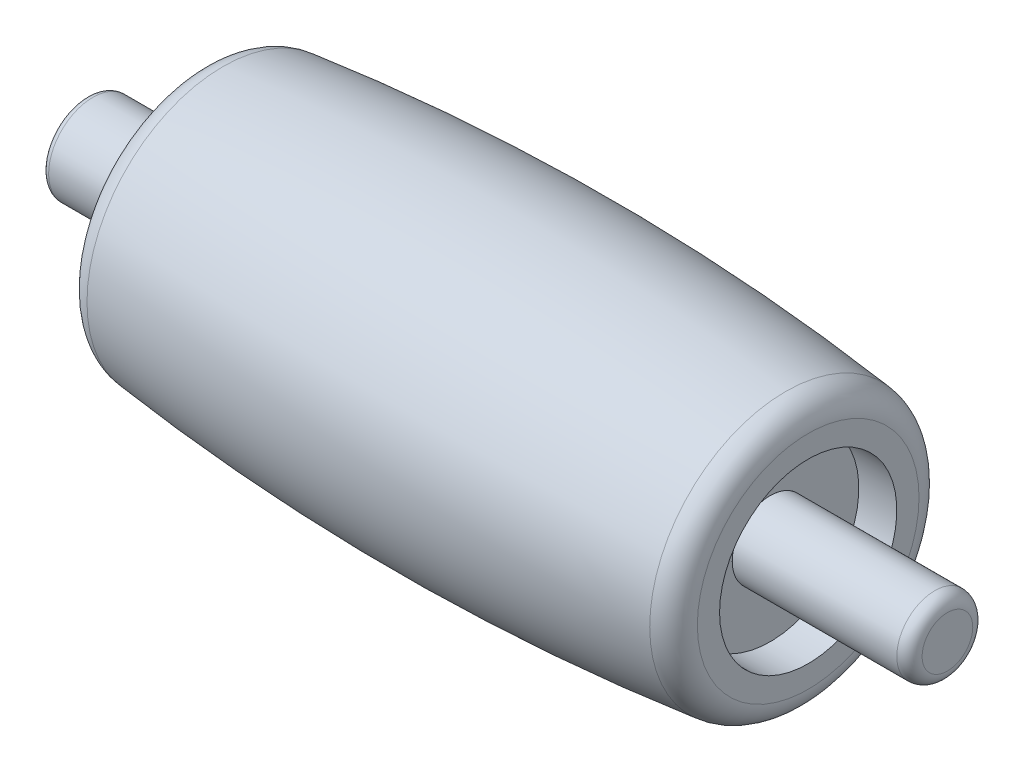
from build123d import *

# Parameters (mm, degrees)
SKETCH2_R           = 1.5
BOSS_EXTRUDE1_DEPTH = 7
SKETCH3_R           = 1.75
BOSS_EXTRUDE2_DEPTH = 6
FILLET1_R           = 0.5
FILLET2_R           = 0.25


with BuildPart() as part:
    # Sketch1 → Revolve2 (revolve)
    with BuildSketch(Plane.XY):
        with BuildLine():
            Line((-10.5, 1.5), (10.5, 1.5))
            Line((10.5, 1.5), (10.5, 3.5))
            Line((10.5, 3.5), (12, 3.5))
            Line((12, 3.5), (12, 4.377499968))
            ThreePointArc((12, 4.377499968), (11.745929123, 5.0435253), (11.112820513, 5.371115352))
            ThreePointArc((11.112820513, 5.371115352), (0, 6), (-11.112820513, 5.371115352))
            ThreePointArc((-11.112820513, 5.371115352), (-11.745929123, 5.0435253), (-12, 4.377499968))
            Line((-12, 4.377499968), (-12, 3.5))
            Line((-12, 3.5), (-10.5, 3.5))
            Line((-10.5, 3.5), (-10.5, 1.5))
        make_face()
    revolve(axis=Axis((0, 0, 0), (1, 0, 0)))


with BuildPart() as body_2:
    # Sketch2 → Boss-Extrude1 (new body)
    with BuildSketch(Plane(origin=(10.5, 0, 0), x_dir=(0, 0, -1), z_dir=(1, 0, 0))):
        Circle(SKETCH2_R)
    extrude(amount=BOSS_EXTRUDE1_DEPTH)

    # Fillet1
    fillet1_edges = [body_2.edges().sort_by_distance(p)[0] for p in [
        (17.5, 0, 1.5),
    ]]
    fillet(fillet1_edges, radius=FILLET1_R)


with BuildPart() as body_3:
    # Sketch3 → Boss-Extrude2 (new body)
    with BuildSketch(Plane.ZY.offset(10.5)):
        Circle(SKETCH3_R)
    extrude(amount=BOSS_EXTRUDE2_DEPTH)

    # Fillet2
    fillet2_edges = [body_3.edges().sort_by_distance(p)[0] for p in [
        (-16.5, 0, -1.75),
    ]]
    fillet(fillet2_edges, radius=FILLET2_R)


solid = Compound([part.part, body_2.part, body_3.part])
